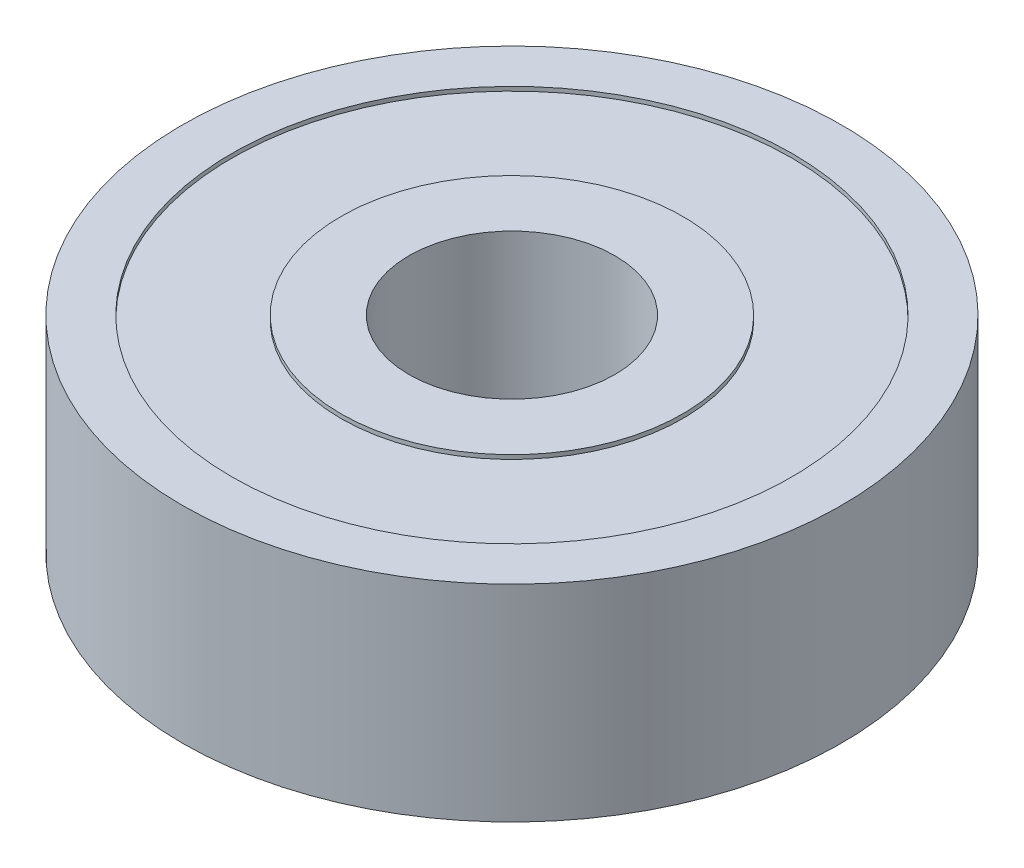
from build123d import *

# Parameters (mm, degrees)
SKETCH1_R           = 8
SKETCH1_R_2         = 2.5
BOSS_EXTRUDE1_DEPTH = 5
SKETCH2_R           = 6.8
SKETCH2_R_2         = 4.15
CUT_EXTRUDE1_DEPTH  = 0.1
SKETCH3_R           = 6.8
SKETCH3_R_2         = 4.15
CUT_EXTRUDE2_DEPTH  = 0.1


with BuildPart() as part:
    # Sketch1 → Boss-Extrude1 (new body)
    with BuildSketch(Plane(origin=(0, 0, 0), x_dir=(1, 0, 0), z_dir=(0, 1, 0))):
        Circle(SKETCH1_R)
        Circle(SKETCH1_R_2, mode=Mode.SUBTRACT)
    extrude(amount=BOSS_EXTRUDE1_DEPTH)

    # Sketch2 → Cut-Extrude1 (cut)
    with BuildSketch(Plane(origin=(0, 5, 0), x_dir=(1, 0, 0), z_dir=(0, 1, 0))):
        Circle(SKETCH2_R)
        Circle(SKETCH2_R_2, mode=Mode.SUBTRACT)
    extrude(amount=-CUT_EXTRUDE1_DEPTH, mode=Mode.SUBTRACT)

    # Sketch3 → Cut-Extrude2 (cut)
    with BuildSketch(Plane.XZ):
        Circle(SKETCH3_R)
        Circle(SKETCH3_R_2, mode=Mode.SUBTRACT)
    extrude(amount=-CUT_EXTRUDE2_DEPTH, mode=Mode.SUBTRACT)


solid = part.part
